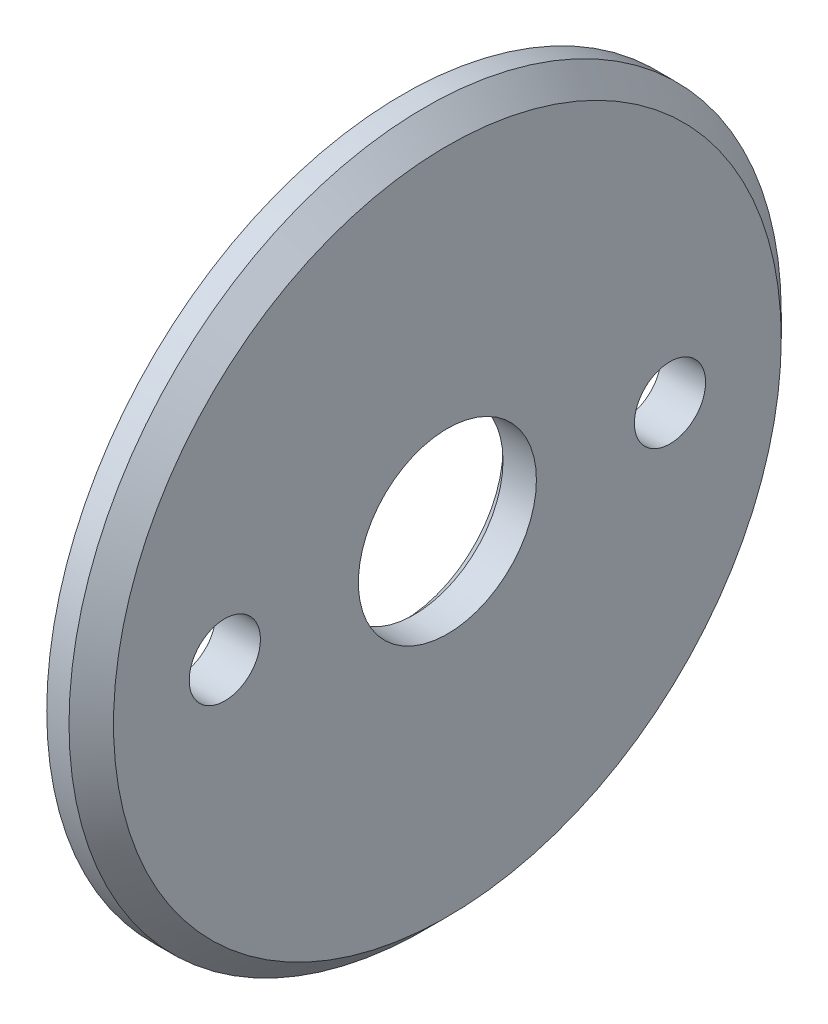
from build123d import *

# Parameters (mm, degrees)
SKETCH1_R           = 16
SKETCH1_R_2         = 4
BOSS_EXTRUDE1_DEPTH = 2
SKETCH2_R           = 1.6
CUT_EXTRUDE1_DEPTH  = 3
CHAMFER1_SIZE       = 1
CHAMFER2_SIZE       = 0.5


with BuildPart() as part:
    # Sketch1 → Boss-Extrude1 (new body)
    with BuildSketch(Plane(origin=(0, 0, 0), x_dir=(0, 0, -1), z_dir=(1, 0, 0))):
        Circle(SKETCH1_R)
        Circle(SKETCH1_R_2, mode=Mode.SUBTRACT)
    extrude(amount=BOSS_EXTRUDE1_DEPTH)

    # Sketch2 → Cut-Extrude1 (cut, through all)
    with BuildSketch(Plane(origin=(2, 0, 0), x_dir=(0, 0, -1), z_dir=(1, 0, 0))):
        with Locations((-10, 0)):
            Circle(SKETCH2_R)
        with Locations((10, 0)):
            Circle(SKETCH2_R)
    extrude(amount=-CUT_EXTRUDE1_DEPTH, mode=Mode.SUBTRACT)

    # Chamfer1
    chamfer1_edges = [part.edges().sort_by_distance(p)[0] for p in [
        (2, 0, 16),
    ]]
    chamfer(chamfer1_edges, length=CHAMFER1_SIZE)

    # Chamfer2
    chamfer2_edges = [part.edges().sort_by_distance(p)[0] for p in [
        (0, 0, 4),
    ]]
    chamfer(chamfer2_edges, length=CHAMFER2_SIZE)


solid = part.part
